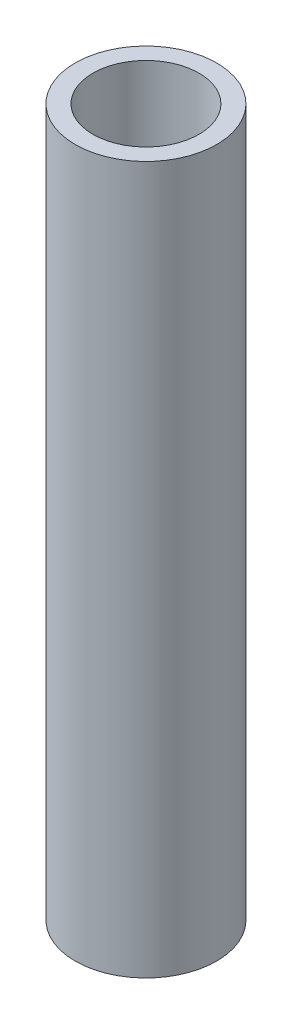
from build123d import *

# Parameters (mm, degrees)
SKETCH1_R           = 20
SKETCH1_R_2         = 15
BOSS_EXTRUDE1_DEPTH = 200


with BuildPart() as part:
    # Sketch1 → Boss-Extrude1 (new body)
    with BuildSketch(Plane(origin=(0, 0, 0), x_dir=(1, 0, 0), z_dir=(0, 1, 0))):
        Circle(SKETCH1_R)
        Circle(SKETCH1_R_2, mode=Mode.SUBTRACT)
    extrude(amount=BOSS_EXTRUDE1_DEPTH)


solid = part.part
